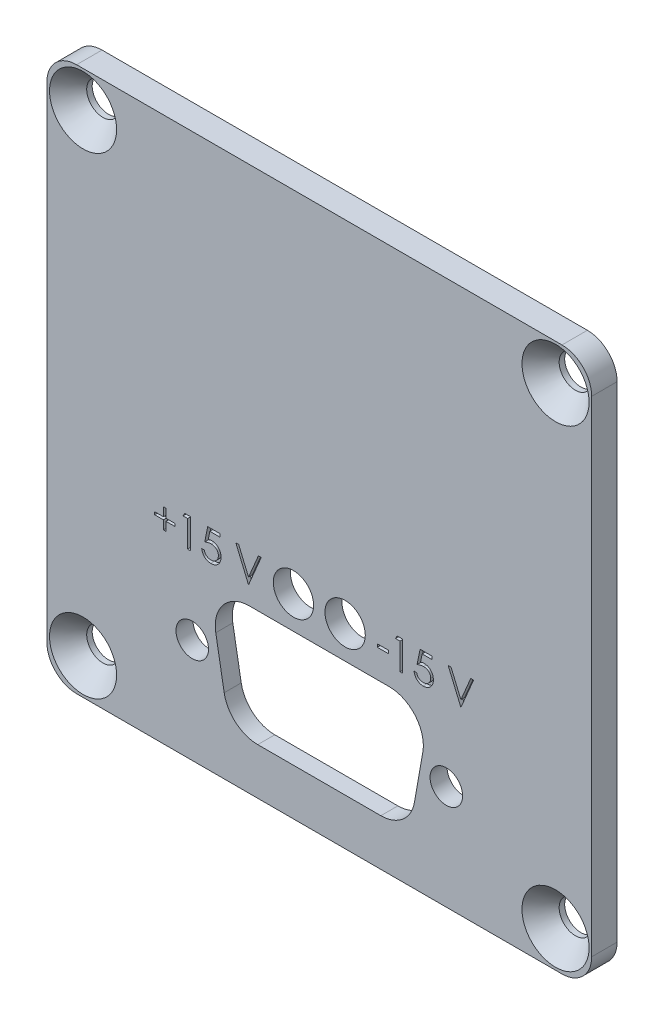
from build123d import *

# Parameters (mm, degrees)
BOSS_EXTRUDE1_DEPTH                           = 1.25
CSK_FOR_4_FLAT_HEAD_MACHINE_SCREW1_AT_2_COUNT = 2
CSK_FOR_4_FLAT_HEAD_MACHINE_SCREW1_AT_2_PITCH = 65.735474806
CSK_FOR_4_FLAT_HEAD_MACHINE_SCREW1_AT_3_COUNT = 2
CSK_FOR_4_FLAT_HEAD_MACHINE_SCREW1_AT_3_PITCH = 46.482
CSK_FOR_4_FLAT_HEAD_MACHINE_SCREW1_AT_4_COUNT = 2
CSK_FOR_4_FLAT_HEAD_MACHINE_SCREW1_AT_4_PITCH = 46.482
CONNECTOR_LAND_DEPTH                          = 0.8236
F_4_CLEARANCE_HOLE1_D                         = 3.2004
SKETCH10_R                                    = 1.984375
CONNECTOR_CUT_OUT_DEPTH                       = 3.5
SKETCH12_W                                    = 1.119391026
SKETCH12_H                                    = 0.298504273
CUT_EXTRUDE1_DEPTH                            = 0.381


with BuildPart() as part:
    # Sketch1 → Boss-Extrude1 (new body, symmetric)
    with BuildSketch(Plane.XY):
        with BuildLine():
            Line((-23.876, 26.797), (23.876, 26.797))
            ThreePointArc((23.876, 26.797), (25.941458908, 25.941458908), (26.797, 23.876))
            Line((26.797, 23.876), (26.797, -23.876))
            ThreePointArc((26.797, -23.876), (25.941458908, -25.941458908), (23.876, -26.797))
            Line((23.876, -26.797), (-23.876, -26.797))
            ThreePointArc((-23.876, -26.797), (-25.941458908, -25.941458908), (-26.797, -23.876))
            Line((-26.797, -23.876), (-26.797, 23.876))
            ThreePointArc((-26.797, 23.876), (-25.941458908, 25.941458908), (-23.876, 26.797))
        make_face()
    extrude(amount=BOSS_EXTRUDE1_DEPTH, both=True)

    # Sketch5 → CSK for #4 Flat Head Machine Screw1 (revolve, cut)
    with BuildSketch(Plane(origin=(-23.241, 23.241, 1.25), x_dir=(0, -1, 0), z_dir=(1, 0, 0))):
        Polygon((0, 0), (0, 2.5), (1.6002, 2.5), (1.6002, 1.957696955), (3.302, 0), align=None)
    csk_for_4_flat_head_machine_screw1 = revolve(axis=Axis((-23.241, 23.241, 7.6), (0, 0, -1)), mode=Mode.SUBTRACT)

    # CSK for #4 Flat Head Machine Screw1 at 2: CSK for #4 Flat Head Machine Screw1 ×2
    with Locations(*[Vector(0.707106781, -0.707106781, 0) * (i * CSK_FOR_4_FLAT_HEAD_MACHINE_SCREW1_AT_2_PITCH) for i in range(1, CSK_FOR_4_FLAT_HEAD_MACHINE_SCREW1_AT_2_COUNT)]):
        add(csk_for_4_flat_head_machine_screw1, mode=Mode.SUBTRACT)

    # CSK for #4 Flat Head Machine Screw1 at 3: CSK for #4 Flat Head Machine Screw1 ×2
    with Locations(*[(i * CSK_FOR_4_FLAT_HEAD_MACHINE_SCREW1_AT_3_PITCH, 0, 0) for i in range(1, CSK_FOR_4_FLAT_HEAD_MACHINE_SCREW1_AT_3_COUNT)]):
        add(csk_for_4_flat_head_machine_screw1, mode=Mode.SUBTRACT)

    # CSK for #4 Flat Head Machine Screw1 at 4: CSK for #4 Flat Head Machine Screw1 ×2
    with Locations(*[(0, -i * CSK_FOR_4_FLAT_HEAD_MACHINE_SCREW1_AT_4_PITCH, 0) for i in range(1, CSK_FOR_4_FLAT_HEAD_MACHINE_SCREW1_AT_4_COUNT)]):
        add(csk_for_4_flat_head_machine_screw1, mode=Mode.SUBTRACT)

    # Sketch7 → Connector Land (cut)
    with BuildSketch(Plane.XY.offset(-1.25)):
        with BuildLine():
            Line((13.081, -5.09016), (-13.081, -5.09016))
            ThreePointArc((-13.081, -5.09016), (-15.32606403, -6.02009597), (-16.256, -8.26516))
            Line((-16.256, -8.26516), (-16.256, -20.96516))
            ThreePointArc((-16.256, -20.96516), (-15.32606403, -23.21022403), (-13.081, -24.14016))
            Line((-13.081, -24.14016), (13.081, -24.14016))
            ThreePointArc((13.081, -24.14016), (15.32606403, -23.21022403), (16.256, -20.96516))
            Line((16.256, -20.96516), (16.256, -8.26516))
            ThreePointArc((16.256, -8.26516), (15.32606403, -6.02009597), (13.081, -5.09016))
        make_face()
    extrude(amount=CONNECTOR_LAND_DEPTH, mode=Mode.SUBTRACT)

    # #4 Clearance Hole1 (through all)
    with Locations(Plane(origin=(0, 0, -0.4264), x_dir=(-1, 0, 0), z_dir=(0, 0, -1))):
        with Locations((12.5, -16.52016), (-12.5, -16.52016)):
            Hole(F_4_CLEARANCE_HOLE1_D / 2)

    # Sketch10 → Connector Cut-out (cut, through all)
    with BuildSketch(Plane.XY.offset(1.25)):
        with Locations((-2.54, -7.62)):
            Circle(SKETCH10_R)
        with Locations((2.54, -7.62)):
            Circle(SKETCH10_R)
        with BuildLine():
            Line((-9.356702952, -19.45186761), (-10.185263434, -14.75286761))
            ThreePointArc((-10.185263434, -14.75286761), (-9.451793809, -12.015521702), (-6.8834, -10.81786))
            Line((-6.8834, -10.81786), (6.8834, -10.81786))
            ThreePointArc((6.8834, -10.81786), (9.451793809, -12.015521702), (10.185263434, -14.75286761))
            Line((10.185263434, -14.75286761), (9.356702952, -19.45186761))
            ThreePointArc((9.356702952, -19.45186761), (8.209977815, -21.438053809), (6.054839518, -22.22246))
            Line((6.054839518, -22.22246), (-6.054839518, -22.22246))
            ThreePointArc((-6.054839518, -22.22246), (-8.209977815, -21.438053809), (-9.356702952, -19.45186761))
        make_face()
    extrude(amount=-CONNECTOR_CUT_OUT_DEPTH, mode=Mode.SUBTRACT)

    # Sketch12 → Cut-Extrude1 (cut)
    with BuildSketch(Plane.XY.offset(1.25)):
        Polygon((-15.339022009, -7.449852564), (-15.339022009, -6.591652778), (-15.077830769, -6.591652778), (-15.077830769, -7.449852564), (-14.219630983, -7.449852564), (-14.219630983, -7.711043803), (-15.077830769, -7.711043803), (-15.077830769, -8.56924359), (-15.339022009, -8.56924359), (-15.339022009, -7.711043803), (-16.197221795, -7.711043803), (-16.197221795, -7.449852564), align=None)
        Polygon((-13.227920496, -6.106583333), (-12.689796581, -6.106583333), (-12.689796581, -9.017), (-12.950987821, -9.017), (-12.950987821, -6.405087607), (-13.398744231, -6.405087607), align=None)
        with BuildLine():
            Line((-9.779379915, -6.106583333), (-9.779379915, -6.405087607))
            Line((-9.779379915, -6.405087607), (-10.769341353, -6.405087607))
            Line((-10.769341353, -6.405087607), (-10.9261727, -7.170587824))
            add(Edge.make_bspline(
                [(-10.9261727, -7.170587824), (-10.895358976, -7.162080866), (-10.835662259, -7.14559998), (-10.747551588, -7.127301134), (-10.663904381, -7.116270285), (-10.609624802, -7.114764094), (-10.583359198, -7.114035256)],
                knots=[0, 0, 0, 0, 1.100273476, 2.13160584, 3.095893838, 4, 4, 4, 4], degree=3))
            add(Edge.make_bspline(
                [(-10.583359198, -7.114035256), (-10.550859207, -7.114738692), (-10.486956106, -7.116121823), (-10.393457767, -7.129403176), (-10.304205355, -7.150308212), (-10.219385527, -7.179512599), (-10.138841367, -7.21685718), (-10.063313924, -7.263506952), (-9.991669517, -7.318001038), (-9.925193443, -7.380654003), (-9.864886027, -7.449607276), (-9.811861571, -7.523746291), (-9.766822798, -7.602350544), (-9.730599956, -7.68617105), (-9.701675125, -7.774281132), (-9.682423139, -7.867607868), (-9.669603411, -7.965271573), (-9.668171165, -8.032048647), (-9.667440812, -8.066100644)],
                knots=[0, 0, 0, 0, 1.052922333, 2.070308379, 3.05430497, 4.020497103, 4.973039431, 5.925935799, 6.892292201, 7.88610001, 8.88166317, 9.857072816, 10.836096531, 11.812156883, 12.81219415, 13.836441305, 14.89672472, 16, 16, 16, 16], degree=3))
            add(Edge.make_bspline(
                [(-9.667440812, -8.066100644), (-9.667993854, -8.089818229), (-9.669092463, -8.136932875), (-9.674679289, -8.206902785), (-9.685435953, -8.275391402), (-9.699878042, -8.342407814), (-9.718623136, -8.407825143), (-9.741315284, -8.471830634), (-9.769085671, -8.534025911), (-9.799546404, -8.594999469), (-9.833844815, -8.65337287), (-9.871911824, -8.707963129), (-9.912130033, -8.759589165), (-9.955404923, -8.807697299), (-10.002138727, -8.851971404), (-10.051765461, -8.892674231), (-10.103889127, -8.930494123), (-10.159316135, -8.96389589), (-10.216811402, -8.994632348), (-10.277205223, -9.019847813), (-10.339122841, -9.042391508), (-10.403455419, -9.06036086), (-10.470057238, -9.074441085), (-10.539038084, -9.084004382), (-10.610036177, -9.090969789), (-10.658162006, -9.091405816), (-10.682471945, -9.091626068)],
                knots=[0, 0, 0, 0, 1.056347294, 2.098418968, 3.122841568, 4.141288669, 5.149314143, 6.15115421, 7.162517403, 8.180376062, 9.185164535, 10.17417709, 11.141909838, 12.097768115, 13.052685741, 14.0056014, 14.954263652, 15.917497458, 16.885230207, 17.854509472, 18.828990115, 19.81800267, 20.826176721, 21.857883937, 22.917946725, 24, 24, 24, 24], degree=3))
            add(Edge.make_bspline(
                [(-10.682471945, -9.091626068), (-10.711471487, -9.091051604), (-10.76852466, -9.089921412), (-10.852112298, -9.078098065), (-10.932535098, -9.061164499), (-11.009145665, -9.035688981), (-11.082630578, -9.003768118), (-11.152000541, -8.963424611), (-11.219028082, -8.917706868), (-11.280988389, -8.863755765), (-11.33849499, -8.804785999), (-11.3899732, -8.740792055), (-11.435819395, -8.672830132), (-11.475299402, -8.600570179), (-11.508975435, -8.524202067), (-11.535431113, -8.443439667), (-11.556783888, -8.358704962), (-11.565817339, -8.300368977), (-11.570405556, -8.270739316)],
                knots=[0, 0, 0, 0, 1.0467383, 2.05933395, 3.04377827, 4.011590433, 4.970194871, 5.932262533, 6.905835911, 7.896367577, 8.894135286, 9.877477877, 10.858688626, 11.851381753, 12.8477658, 13.868841284, 14.917554742, 16, 16, 16, 16], degree=3))
            Line((-11.570405556, -8.270739316), (-11.309214316, -8.270739316))
            add(Edge.make_bspline(
                [(-11.309214316, -8.270739316), (-11.302787653, -8.298493426), (-11.290435249, -8.351838365), (-11.263322016, -8.426786868), (-11.230171642, -8.493576127), (-11.190752669, -8.553089644), (-11.143728626, -8.604985697), (-11.090069333, -8.651233932), (-11.029908756, -8.692956941), (-10.963057957, -8.727734564), (-10.892531843, -8.757394831), (-10.818717681, -8.777145496), (-10.743625317, -8.791033084), (-10.692835743, -8.792423233), (-10.667313525, -8.793121795)],
                knots=[0, 0, 0, 0, 1.136247022, 2.183929868, 3.172523383, 4.106158343, 5.02341133, 5.958108904, 6.928429099, 7.938127109, 8.96079061, 9.975095812, 10.982467395, 12, 12, 12, 12], degree=3))
            add(Edge.make_bspline(
                [(-10.667313525, -8.793121795), (-10.642401652, -8.792439279), (-10.59334997, -8.7910954), (-10.521162168, -8.780751769), (-10.451467772, -8.764821336), (-10.384954476, -8.740980986), (-10.320458362, -8.712005944), (-10.259610888, -8.674823229), (-10.200651769, -8.632031773), (-10.145413613, -8.583006528), (-10.094822714, -8.528981133), (-10.050121939, -8.471207372), (-10.012887803, -8.409575684), (-9.981510095, -8.345153069), (-9.957683513, -8.277233459), (-9.940685863, -8.20613516), (-9.930704748, -8.131682561), (-9.929331713, -8.080900521), (-9.928632051, -8.055023337)],
                knots=[0, 0, 0, 0, 1.027316725, 2.022795036, 3.002884548, 3.971462791, 4.93288096, 5.914575861, 6.907176829, 7.935150275, 8.956128384, 9.956726525, 10.942570165, 11.921478529, 12.907843606, 13.90538589, 14.932640048, 16, 16, 16, 16], degree=3))
            add(Edge.make_bspline(
                [(-9.928632051, -8.055023337), (-9.929179608, -8.031677013), (-9.930251373, -7.985979905), (-9.939008044, -7.919124136), (-9.954239479, -7.855865779), (-9.975380646, -7.795899359), (-10.002222593, -7.739168318), (-10.03502408, -7.685614107), (-10.074400686, -7.63594258), (-10.119380667, -7.590130498), (-10.16865655, -7.547850564), (-10.223076138, -7.511807892), (-10.281500613, -7.481486408), (-10.34322606, -7.455319269), (-10.409720681, -7.436525673), (-10.479667666, -7.422416068), (-10.553822345, -7.414254127), (-10.604522376, -7.413121651), (-10.630583507, -7.41253953)],
                knots=[0, 0, 0, 0, 1.045622112, 2.046656509, 3.013763289, 3.955457236, 4.890082067, 5.820317437, 6.762574623, 7.722996705, 8.69280354, 9.665887285, 10.63943826, 11.638615906, 12.663482002, 13.728887084, 14.832589034, 16, 16, 16, 16], degree=3))
            add(Edge.make_bspline(
                [(-10.630583507, -7.41253953), (-10.653142503, -7.413022319), (-10.699721107, -7.414019156), (-10.771170029, -7.421358809), (-10.846251896, -7.43319946), (-10.92467889, -7.449486358), (-11.006686539, -7.470799818), (-11.092101781, -7.496340388), (-11.181104207, -7.526876479), (-11.241073529, -7.549937135), (-11.271901282, -7.561791667)],
                knots=[0, 0, 0, 0, 0.817624296, 1.688186739, 2.600797293, 3.572016777, 4.590301741, 5.671205678, 6.80286297, 8, 8, 8, 8], degree=3))
            Line((-11.271901282, -7.561791667), (-10.973397009, -6.106583333))
            Line((-10.973397009, -6.106583333), (-9.779379915, -6.106583333))
        make_face()
        Polygon((-8.212232479, -6.106583333), (-7.932384722, -6.106583333), (-6.962245833, -8.400168904), (-5.992106944, -6.106583333), (-5.712259188, -6.106583333), (-6.943589316, -9.017), (-6.98090235, -9.017), align=None)
        Polygon((12.679674573, -6.106583333), (12.959522329, -6.106583333), (13.929661218, -8.400168904), (14.899800107, -6.106583333), (15.179647863, -6.106583333), (13.948317735, -9.017), (13.911004701, -9.017), align=None)
        with BuildLine():
            Line((11.112527137, -6.106583333), (11.112527137, -6.405087607))
            Line((11.112527137, -6.405087607), (10.122565698, -6.405087607))
            Line((10.122565698, -6.405087607), (9.965734352, -7.170587824))
            add(Edge.make_bspline(
                [(9.965734352, -7.170587824), (9.996548076, -7.162080866), (10.056244793, -7.14559998), (10.144355463, -7.127301134), (10.22800267, -7.116270285), (10.282282249, -7.114764094), (10.308547853, -7.114035256)],
                knots=[0, 0, 0, 0, 1.100273476, 2.13160584, 3.095893838, 4, 4, 4, 4], degree=3))
            add(Edge.make_bspline(
                [(10.308547853, -7.114035256), (10.341047844, -7.114738692), (10.404950946, -7.116121823), (10.498449284, -7.129403176), (10.587701696, -7.150308212), (10.672521524, -7.179512599), (10.753065685, -7.21685718), (10.828593127, -7.263506952), (10.900237534, -7.318001038), (10.966713608, -7.380654003), (11.027021024, -7.449607276), (11.080045481, -7.523746291), (11.125084254, -7.602350544), (11.161307096, -7.68617105), (11.190231926, -7.774281132), (11.209483912, -7.867607868), (11.22230364, -7.965271573), (11.223735886, -8.032048647), (11.224466239, -8.066100644)],
                knots=[0, 0, 0, 0, 1.052922333, 2.070308379, 3.05430497, 4.020497103, 4.973039431, 5.925935799, 6.892292201, 7.88610001, 8.88166317, 9.857072816, 10.836096531, 11.812156883, 12.81219415, 13.836441305, 14.89672472, 16, 16, 16, 16], degree=3))
            add(Edge.make_bspline(
                [(11.224466239, -8.066100644), (11.223913198, -8.089818229), (11.222814588, -8.136932875), (11.217227762, -8.206902785), (11.206471098, -8.275391402), (11.192029009, -8.342407814), (11.173283915, -8.407825143), (11.150591767, -8.471830634), (11.12282138, -8.534025911), (11.092360647, -8.594999469), (11.058062236, -8.65337287), (11.019995228, -8.707963129), (10.979777019, -8.759589165), (10.936502128, -8.807697299), (10.889768325, -8.851971404), (10.84014159, -8.892674231), (10.788017925, -8.930494123), (10.732590917, -8.96389589), (10.675095649, -8.994632348), (10.614701828, -9.019847813), (10.55278421, -9.042391508), (10.488451632, -9.06036086), (10.421849813, -9.074441085), (10.352868967, -9.084004382), (10.281870874, -9.090969789), (10.233745045, -9.091405816), (10.209435106, -9.091626068)],
                knots=[0, 0, 0, 0, 1.056347294, 2.098418968, 3.122841568, 4.141288669, 5.149314143, 6.15115421, 7.162517403, 8.180376062, 9.185164535, 10.17417709, 11.141909838, 12.097768115, 13.052685741, 14.0056014, 14.954263652, 15.917497458, 16.885230207, 17.854509472, 18.828990115, 19.81800267, 20.826176721, 21.857883937, 22.917946725, 24, 24, 24, 24], degree=3))
            add(Edge.make_bspline(
                [(10.209435106, -9.091626068), (10.180435564, -9.091051604), (10.123382391, -9.089921412), (10.039794753, -9.078098065), (9.959371953, -9.061164499), (9.882761387, -9.035688981), (9.809276473, -9.003768118), (9.73990651, -8.963424611), (9.672878969, -8.917706868), (9.610918663, -8.863755765), (9.553412061, -8.804785999), (9.501933851, -8.740792055), (9.456087657, -8.672830132), (9.416607649, -8.600570179), (9.382931616, -8.524202067), (9.356475938, -8.443439667), (9.335123163, -8.358704962), (9.326089712, -8.300368977), (9.321501496, -8.270739316)],
                knots=[0, 0, 0, 0, 1.0467383, 2.05933395, 3.04377827, 4.011590433, 4.970194871, 5.932262533, 6.905835911, 7.896367577, 8.894135286, 9.877477877, 10.858688626, 11.851381753, 12.8477658, 13.868841284, 14.917554742, 16, 16, 16, 16], degree=3))
            Line((9.321501496, -8.270739316), (9.582692735, -8.270739316))
            add(Edge.make_bspline(
                [(9.582692735, -8.270739316), (9.589119399, -8.298493426), (9.601471803, -8.351838365), (9.628585035, -8.426786868), (9.661735409, -8.493576127), (9.701154382, -8.553089644), (9.748178425, -8.604985697), (9.801837718, -8.651233932), (9.861998295, -8.692956941), (9.928849094, -8.727734564), (9.999375208, -8.757394831), (10.07318937, -8.777145496), (10.148281735, -8.791033084), (10.199071308, -8.792423233), (10.224593526, -8.793121795)],
                knots=[0, 0, 0, 0, 1.136247022, 2.183929868, 3.172523383, 4.106158343, 5.02341133, 5.958108904, 6.928429099, 7.938127109, 8.96079061, 9.975095812, 10.982467395, 12, 12, 12, 12], degree=3))
            add(Edge.make_bspline(
                [(10.224593526, -8.793121795), (10.249505399, -8.792439279), (10.298557081, -8.7910954), (10.370744883, -8.780751769), (10.440439279, -8.764821336), (10.506952575, -8.740980986), (10.571448689, -8.712005944), (10.632296164, -8.674823229), (10.691255282, -8.632031773), (10.746493439, -8.583006528), (10.797084338, -8.528981133), (10.841785112, -8.471207372), (10.879019248, -8.409575684), (10.910396956, -8.345153069), (10.934223539, -8.277233459), (10.951221188, -8.20613516), (10.961202303, -8.131682561), (10.962575338, -8.080900521), (10.963275, -8.055023337)],
                knots=[0, 0, 0, 0, 1.027316725, 2.022795036, 3.002884548, 3.971462791, 4.93288096, 5.914575861, 6.907176829, 7.935150275, 8.956128384, 9.956726525, 10.942570165, 11.921478529, 12.907843606, 13.90538589, 14.932640048, 16, 16, 16, 16], degree=3))
            add(Edge.make_bspline(
                [(10.963275, -8.055023337), (10.962727443, -8.031677013), (10.961655678, -7.985979905), (10.952899007, -7.919124136), (10.937667573, -7.855865779), (10.916526406, -7.795899359), (10.889684458, -7.739168318), (10.856882971, -7.685614107), (10.817506366, -7.63594258), (10.772526384, -7.590130498), (10.723250502, -7.547850564), (10.668830913, -7.511807892), (10.610406438, -7.481486408), (10.548680992, -7.455319269), (10.482186371, -7.436525673), (10.412239385, -7.422416068), (10.338084706, -7.414254127), (10.287384676, -7.413121651), (10.261323544, -7.41253953)],
                knots=[0, 0, 0, 0, 1.045622112, 2.046656509, 3.013763289, 3.955457236, 4.890082067, 5.820317437, 6.762574623, 7.722996705, 8.69280354, 9.665887285, 10.63943826, 11.638615906, 12.663482002, 13.728887084, 14.832589034, 16, 16, 16, 16], degree=3))
            add(Edge.make_bspline(
                [(10.261323544, -7.41253953), (10.238764548, -7.413022319), (10.192185944, -7.414019156), (10.120737022, -7.421358809), (10.045655155, -7.43319946), (9.967228161, -7.449486358), (9.885220512, -7.470799818), (9.799805271, -7.496340388), (9.710802844, -7.526876479), (9.650833522, -7.549937135), (9.620005769, -7.561791667)],
                knots=[0, 0, 0, 0, 0.817624296, 1.688186739, 2.600797293, 3.572016777, 4.590301741, 5.671205678, 6.80286297, 8, 8, 8, 8], degree=3))
            Line((9.620005769, -7.561791667), (9.918510043, -6.106583333))
            Line((9.918510043, -6.106583333), (11.112527137, -6.106583333))
        make_face()
        Polygon((7.663986555, -6.106583333), (8.20211047, -6.106583333), (8.20211047, -9.017), (7.940919231, -9.017), (7.940919231, -6.405087607), (7.493162821, -6.405087607), align=None)
        with Locations((6.261832692, -7.897608975)):
            Rectangle(SKETCH12_W, SKETCH12_H)
    extrude(amount=-CUT_EXTRUDE1_DEPTH, mode=Mode.SUBTRACT)


solid = part.part
